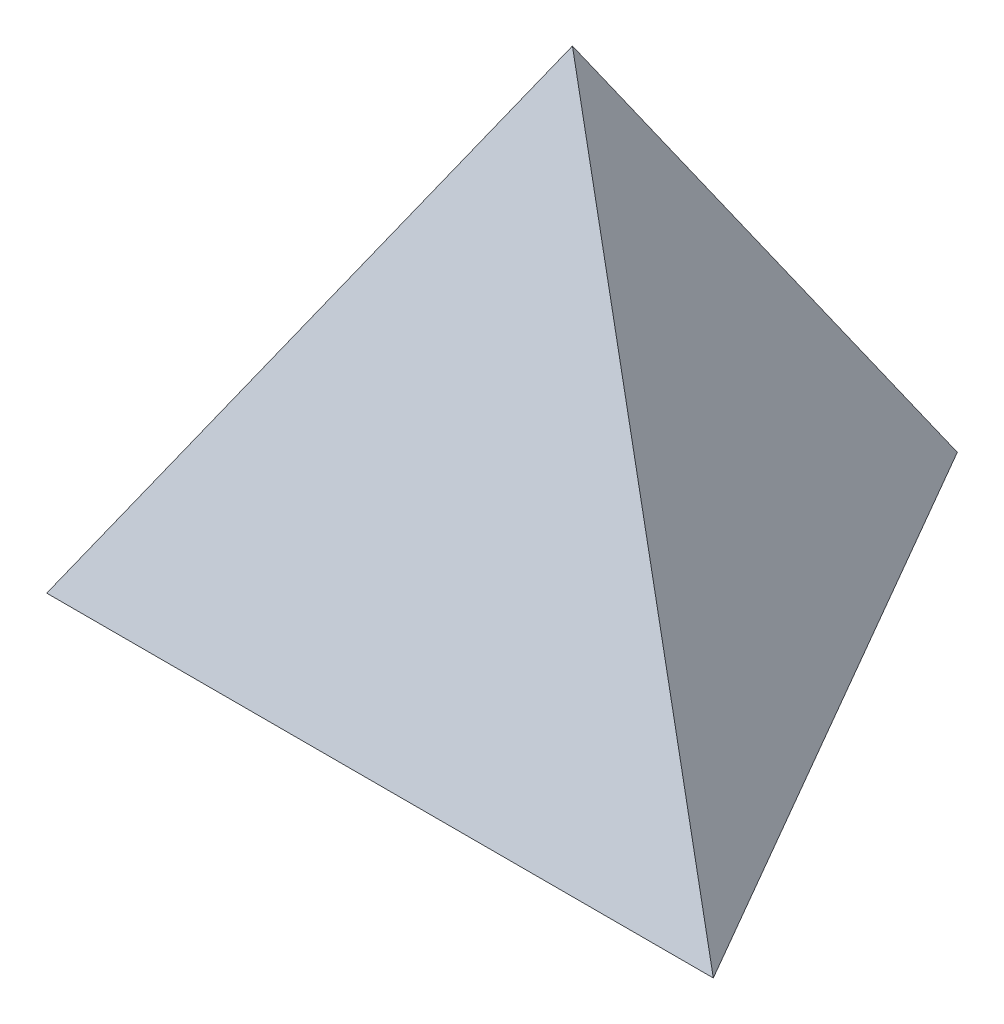
from build123d import *

# Parameters (mm, degrees)
BOSS_EXTRUDE1_DEPTH = 50.799999619


with BuildPart() as part:
    # Sketch1 → Boss-Extrude1 (new, along a direction that is not the sketch's normal)
    with BuildSketch(Plane(origin=(0, 0, 0), x_dir=(1, 0, 0), z_dir=(0, 1, 0))):
        Polygon((-25.4, -14.664696837), (25.4, -14.664696837), (0, 29.329393675), align=None)
    extrude(amount=BOSS_EXTRUDE1_DEPTH, dir=(0, 0.8164965809277261, 0.5773502691896257))

    # SurfaceCut1
    split(bisect_by=Plane(origin=(0, 4.60866959, 13.035286078), x_dir=(1, 0, 0), z_dir=(0, 0.3333333333333331, 0.9428090415820635)), keep=Keep.BOTTOM)


solid = part.part
